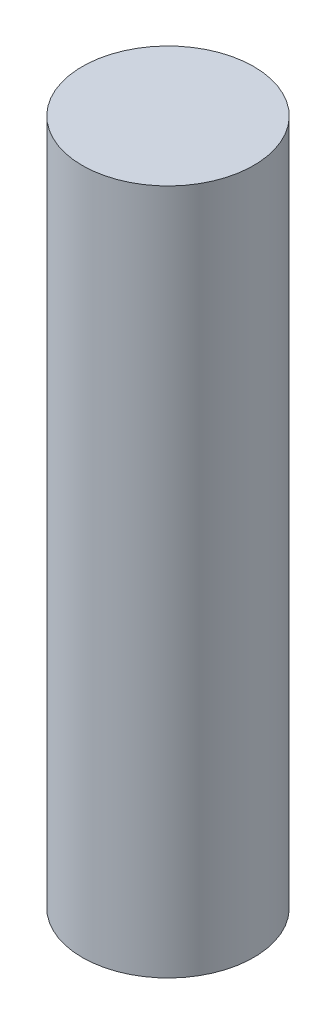
from build123d import *

# Parameters (mm, degrees)
SKETCH1_R           = 1.5
BOSS_EXTRUDE1_DEPTH = 12


with BuildPart() as part:
    # Sketch1 → Boss-Extrude1 (new body)
    with BuildSketch(Plane(origin=(0, 0, 0), x_dir=(1, 0, 0), z_dir=(0, 1, 0))):
        Circle(SKETCH1_R)
    extrude(amount=BOSS_EXTRUDE1_DEPTH)


solid = part.part
